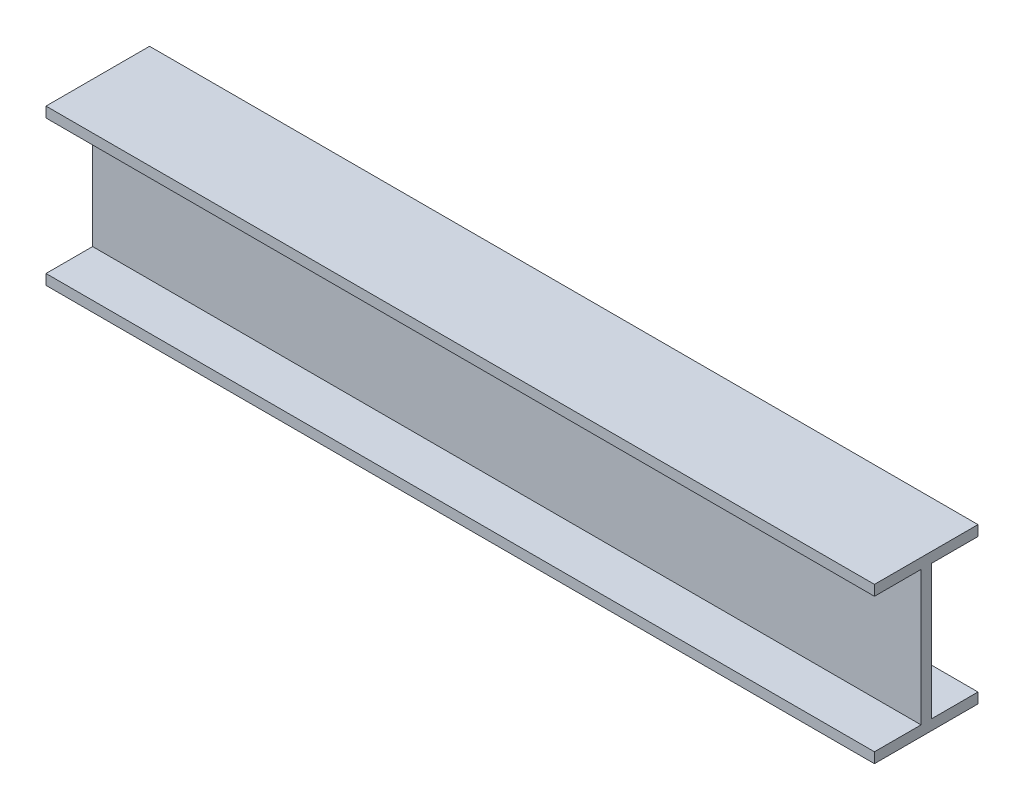
from build123d import *

# Parameters (mm, degrees)
BOSS_EXTRUDE1_DEPTH = 400


with BuildPart() as part:
    # Sketch1 → Boss-Extrude1 (new body, symmetric)
    with BuildSketch(Plane(origin=(0, 0, 0), x_dir=(0, 0, -1), z_dir=(1, 0, 0))):
        Polygon((-50, 28.256269625), (50, 28.256269625), (50, 18.256269625), (5, 18.256269625), (5, -111.743730375), (50, -111.743730375), (50, -121.743730375), (-50, -121.743730375), (-50, -111.743730375), (-5, -111.743730375), (-5, 18.256269625), (-50, 18.256269625), align=None)
    extrude(amount=BOSS_EXTRUDE1_DEPTH, both=True)


solid = part.part
